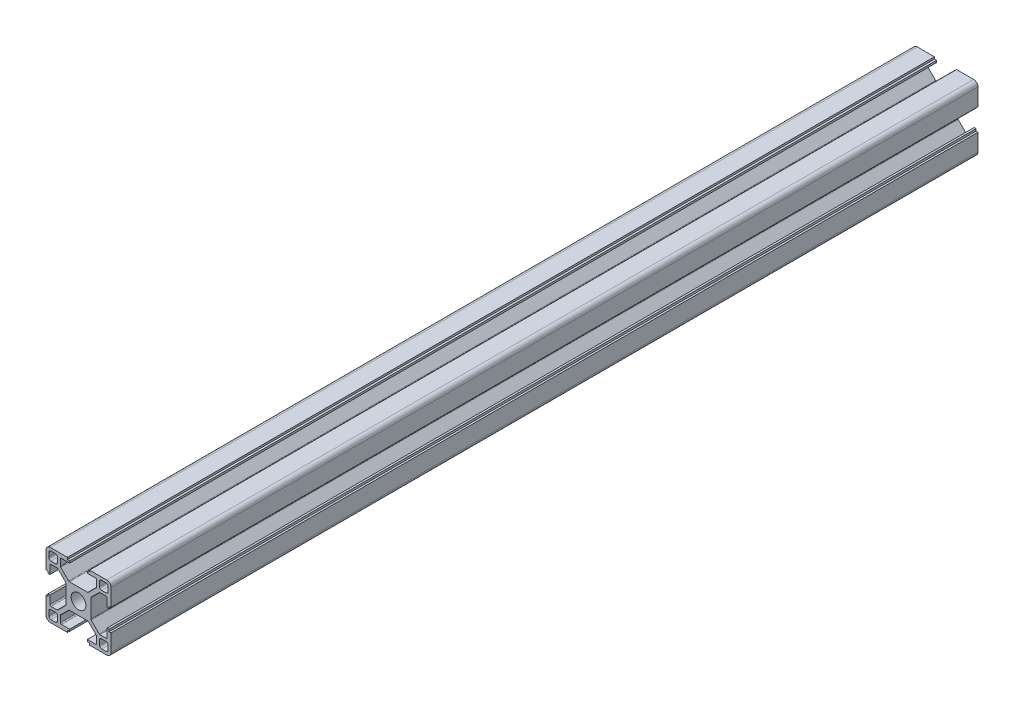
from build123d import *

# Parameters (mm, degrees)
SKETCH_1_W                       = 4
SKETCH_1_H                       = 4
EXTRUDE_1_DEPTH                  = 400
FILLET_1_R                       = 1
FILLET_2_R                       = 2
FILLET_3_R                       = 0.5
PATTERN_CIRCULAR_1_COUNT         = 4
FILLET_1_OF_PATTERN_CIRCULAR_1_R = 1
FILLET_2_OF_PATTERN_CIRCULAR_1_R = 2
FILLET_3_OF_PATTERN_CIRCULAR_1_R = 0.5
SKETCH_2_R                       = 3.4
CUT_EXTRUDE_1_DEPTH              = 401
SKETCH_3_R                       = 2.75
CUT_EXTRUDE_2_DEPTH              = 10


with BuildPart() as part:
    # 草图1 → 凸台-拉伸1 (new body)
    with BuildSketch(Plane.XY):
        Polygon((5.7, 0), (5.7, 4.427207794), (9.672792206, 8.4), (13.2, 8.4), (13.2, 4.1), (14.1, 4.1), (14.1, 5.1), (15, 5.1), (15, 15), (5.1, 15), (5.1, 14.1), (4.1, 14.1), (4.1, 13.2), (8.4, 13.2), (8.4, 9.672792206), (4.427207794, 5.7), (0, 5.7), (0, 0), align=None)
        with Locations((11.7, 11.7)):
            Rectangle(SKETCH_1_W, SKETCH_1_H, mode=Mode.SUBTRACT)
    extrude_1 = extrude(amount=EXTRUDE_1_DEPTH)

    # 圆角1
    fillet_1_edges = [part.edges().sort_by_distance(p)[0] for p in [
        (13.7, 9.7, 200),
        (13.7, 13.7, 200),
        (9.7, 13.7, 200),
        (9.7, 9.7, 200),
    ]]
    fillet(fillet_1_edges, radius=FILLET_1_R)

    # 圆角2
    fillet_2_edges = [part.edges().sort_by_distance(p)[0] for p in [
        (15, 15, 200),
    ]]
    fillet(fillet_2_edges, radius=FILLET_2_R)

    # 圆角3
    fillet_3_edges = [part.edges().sort_by_distance(p)[0] for p in [
        (4.427207794, 5.7, 200),
        (8.4, 9.672792206, 200),
        (8.4, 13.2, 200),
        (13.2, 8.4, 200),
        (9.672792206, 8.4, 200),
        (5.7, 4.427207794, 200),
    ]]
    fillet(fillet_3_edges, radius=FILLET_3_R)

    # 阵列(圆周)1: 凸台-拉伸1 ×4 about axis
    pattern_circular_1_axis = Axis((0, 0, 0), (0, 0, 1))
    for i in range(1, PATTERN_CIRCULAR_1_COUNT):
        add(extrude_1.rotate(pattern_circular_1_axis, i * 360 / PATTERN_CIRCULAR_1_COUNT))

    # 圆角1 of 阵列(圆周)1
    fillet_1_of_pattern_circular_1_edges = [part.edges().sort_by_distance(p)[0] for p in [
        (-9.7, 13.7, 200),
        (-13.7, 13.7, 200),
        (-13.7, 9.7, 200),
        (-9.7, 9.7, 200),
        (-13.7, -9.7, 200),
        (-13.7, -13.7, 200),
        (-9.7, -13.7, 200),
        (-9.7, -9.7, 200),
        (9.7, -13.7, 200),
        (13.7, -13.7, 200),
        (13.7, -9.7, 200),
        (9.7, -9.7, 200),
    ]]
    fillet(fillet_1_of_pattern_circular_1_edges, radius=FILLET_1_OF_PATTERN_CIRCULAR_1_R)

    # 圆角2 of 阵列(圆周)1
    fillet_2_of_pattern_circular_1_edges = [part.edges().sort_by_distance(p)[0] for p in [
        (-15, 15, 200),
        (-15, -15, 200),
        (15, -15, 200),
    ]]
    fillet(fillet_2_of_pattern_circular_1_edges, radius=FILLET_2_OF_PATTERN_CIRCULAR_1_R)

    # 圆角3 of 阵列(圆周)1
    fillet_3_of_pattern_circular_1_edges = [part.edges().sort_by_distance(p)[0] for p in [
        (-5.7, 4.427207794, 200),
        (-9.672792206, 8.4, 200),
        (-13.2, 8.4, 200),
        (-8.4, 13.2, 200),
        (-8.4, 9.672792206, 200),
        (-4.427207794, 5.7, 200),
        (-4.427207794, -5.7, 200),
        (-8.4, -9.672792206, 200),
        (-8.4, -13.2, 200),
        (-13.2, -8.4, 200),
        (-9.672792206, -8.4, 200),
        (-5.7, -4.427207794, 200),
        (5.7, -4.427207794, 200),
        (9.672792206, -8.4, 200),
        (13.2, -8.4, 200),
        (8.4, -13.2, 200),
        (8.4, -9.672792206, 200),
        (4.427207794, -5.7, 200),
    ]]
    fillet(fillet_3_of_pattern_circular_1_edges, radius=FILLET_3_OF_PATTERN_CIRCULAR_1_R)

    # 草图2 → 切除-拉伸1 (cut, through all)
    with BuildSketch(Plane.XY.offset(400)):
        Circle(SKETCH_2_R)
    extrude(amount=-CUT_EXTRUDE_1_DEPTH, mode=Mode.SUBTRACT)

    # 草图3 → 切除-拉伸2 (cut, symmetric)
    with BuildSketch(Plane(origin=(0, 0, 0), x_dir=(0, 0, -1), z_dir=(0, 1, 0))):
        with Locations((-290, 0)):
            Circle(SKETCH_3_R)
        with Locations((-226, 0)):
            Circle(SKETCH_3_R)
        with Locations((-129.5, 0)):
            Circle(SKETCH_3_R)
        with Locations((-65.5, 0)):
            Circle(SKETCH_3_R)
        with Locations((-50, 0)):
            Circle(SKETCH_3_R)
        with Locations((-350, 0)):
            Circle(SKETCH_3_R)
    extrude(amount=CUT_EXTRUDE_2_DEPTH, both=True, mode=Mode.SUBTRACT)


solid = part.part
